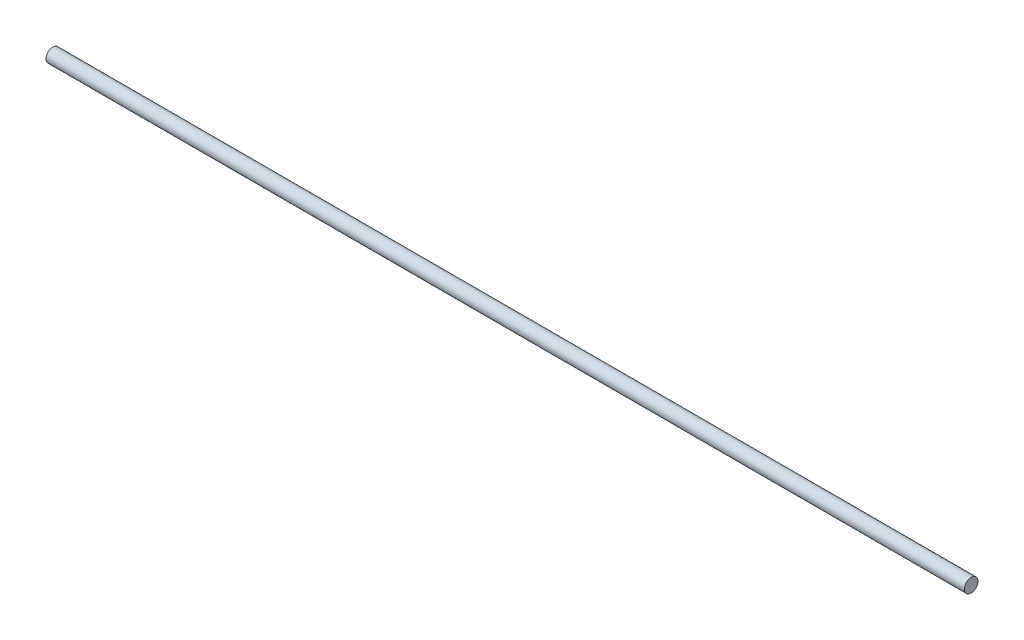
from build123d import *

# Parameters (mm, degrees)
BOSS_EXTRUDE1_START = -9.328425
SKETCH3_R           = 2
BOSS_EXTRUDE1_DEPTH = 270.641


with BuildPart() as part:
    # Sketch3 → Boss-Extrude1 (new body)
    with BuildSketch(Plane(origin=(0, 0, 0), x_dir=(0, 0, -1), z_dir=(1, 0, 0)).offset(BOSS_EXTRUDE1_START)):
        with Locations((0, 9.743400956)):
            Circle(SKETCH3_R)
    extrude(amount=-BOSS_EXTRUDE1_DEPTH)


solid = part.part
